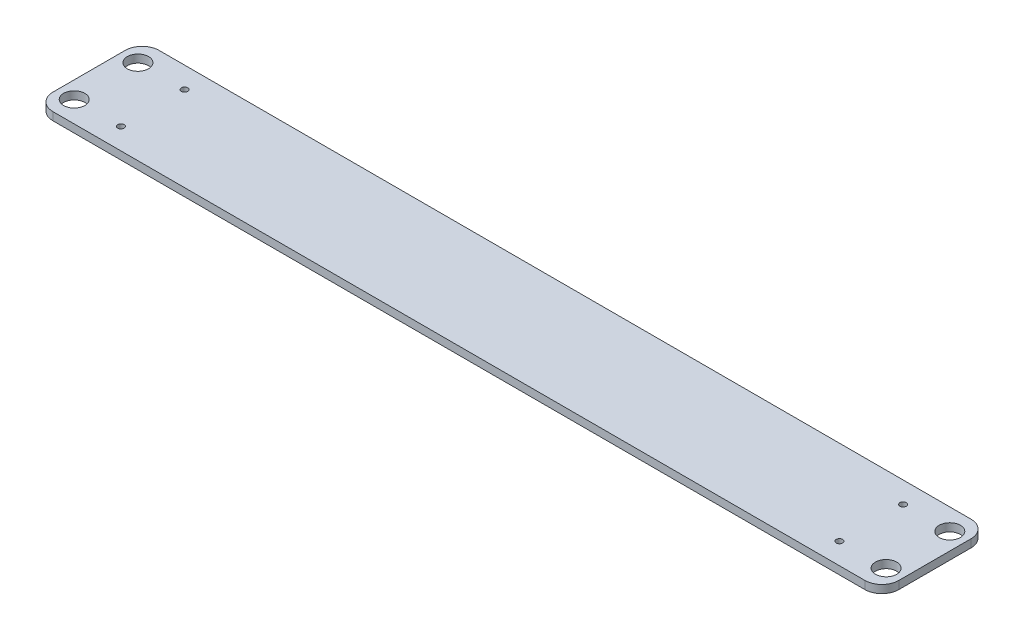
from build123d import *

# Parameters (mm, degrees)
SKETCH1_R           = 6.35
SKETCH1_R_2         = 1.905
BOSS_EXTRUDE1_DEPTH = 4.7625


with BuildPart() as part:
    # Sketch1 → Boss-Extrude1 (new body)
    with BuildSketch(Plane(origin=(0, 0, 0), x_dir=(1, 0, 0), z_dir=(0, 1, 0))):
        with BuildLine():
            Line((10.16, 0), (253.0475, 0))
            Line((253.0475, 0), (253.0475, -63.5))
            Line((253.0475, -63.5), (10.16, -63.5))
            ThreePointArc((10.16, -63.5), (2.975795103, -60.524204897), (0, -53.34))
            Line((0, -53.34), (0, -43.815))
            Line((0, -43.815), (0, -26.035))
            Line((0, -26.035), (0, -10.16))
            ThreePointArc((0, -10.16), (2.975795103, -2.975795103), (10.16, 0))
        make_face()
        with Locations((10.16, -50.8)):
            Circle(SKETCH1_R, mode=Mode.SUBTRACT)
        with Locations((10.16, -12.7)):
            Circle(SKETCH1_R, mode=Mode.SUBTRACT)
        with Locations((38.1, -50.8)):
            Circle(SKETCH1_R_2, mode=Mode.SUBTRACT)
        with Locations((38.1, -12.7)):
            Circle(SKETCH1_R_2, mode=Mode.SUBTRACT)
    boss_extrude1 = extrude(amount=BOSS_EXTRUDE1_DEPTH)

    # Mirror1: Boss-Extrude1 across plane
    add(boss_extrude1.mirror(Plane(origin=(253.0475, 4.7625, 0), x_dir=(0, 0, 1), z_dir=(-1, 0, 0))))


solid = part.part
